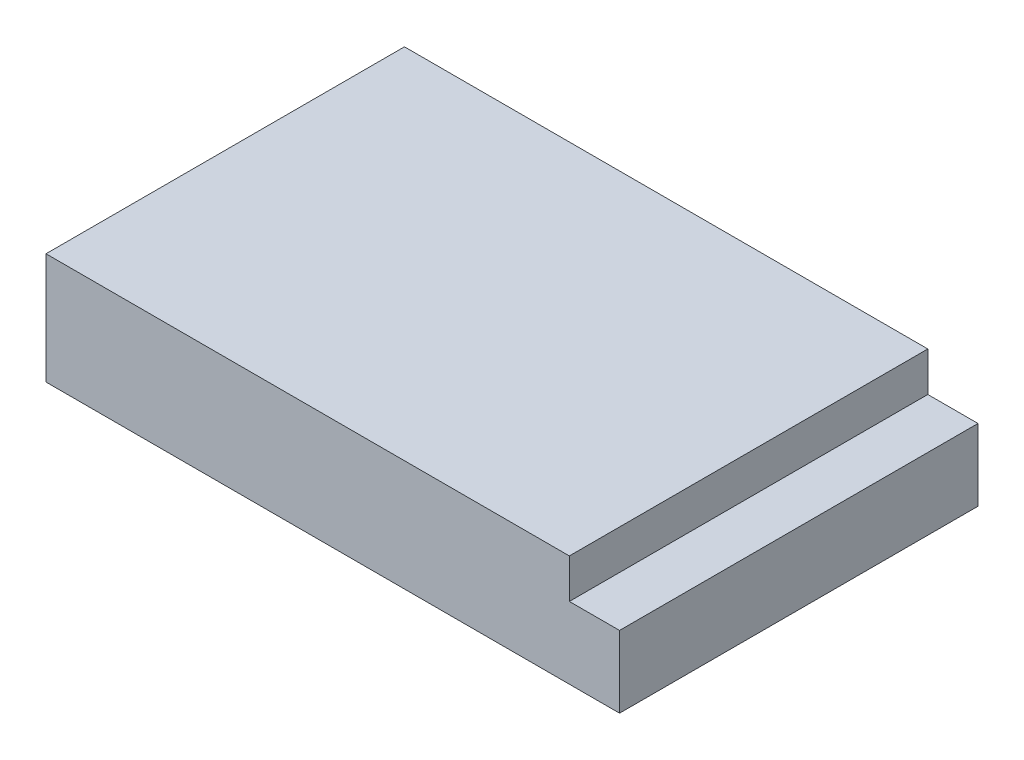
from build123d import *

# Parameters (mm, degrees)
BOSS_EXTRU_1_DEPTH = 100


with BuildPart() as part:
    # Esquisse1 → Boss.-Extru.1 (new body)
    with BuildSketch(Plane.XY):
        Polygon((98.148717949, 11), (98.148717949, 0), (112.148717949, 0), (112.148717949, -20), (-47.851282051, -20), (-47.851282051, 11), align=None)
    extrude(amount=BOSS_EXTRU_1_DEPTH)


solid = part.part
